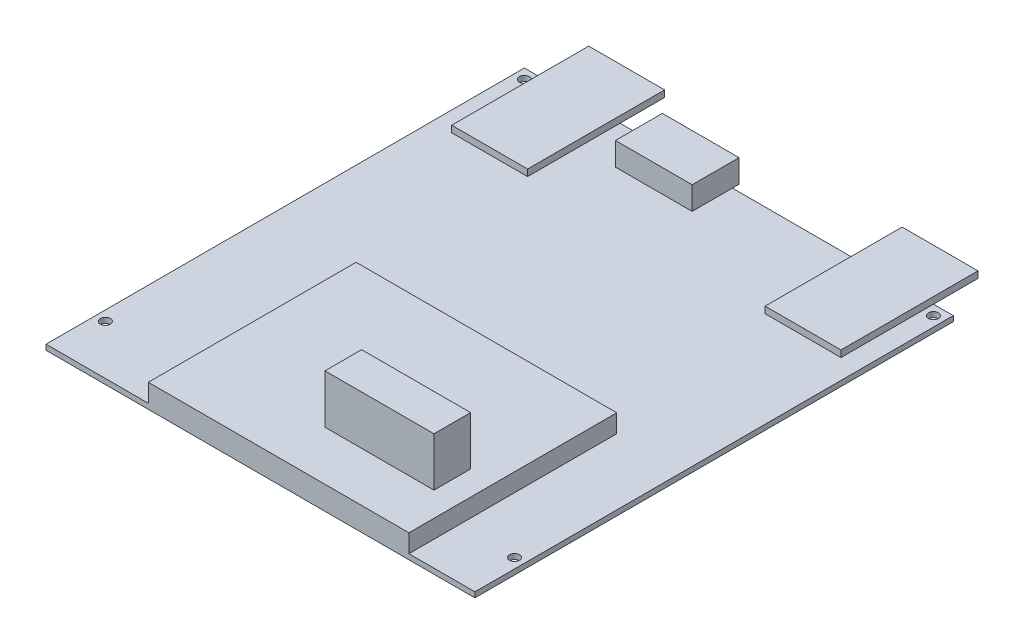
from build123d import *

# Parameters (mm, degrees)
ESQUISSE1_W        = 130
ESQUISSE1_H        = 145
ESQUISSE1_R        = 1.5
BOSS_EXTRU_1_DEPTH = 1.6
ESQUISSE2_W        = 79
ESQUISSE2_H        = 63
BOSS_EXTRU_2_DEPTH = 5.5
ESQUISSE3_W        = 33.047140846
ESQUISSE3_H        = 11.107836296
BOSS_EXTRU_3_DEPTH = 14.8
ESQUISSE4_W        = 23.239665889
ESQUISSE4_H        = 14.216628141
BOSS_EXTRU_4_DEPTH = 7
ESQUISSE5_W        = 23
ESQUISSE5_H        = 41.525911652
BOSS_EXTRU_5_DEPTH = 2
ESQUISSE6_W        = 6.210910455
ESQUISSE6_H        = 46.190495577
BOSS_EXTRU_6_DEPTH = 17.7
ESQUISSE7_W        = 68.5
ESQUISSE7_H        = 96
BOSS_EXTRU_7_DEPTH = 1.6
ESQUISSE8_W        = 5.226174608
ESQUISSE8_H        = 26.34937469
BOSS_EXTRU_8_DEPTH = 5


with BuildPart() as part:
    # Esquisse1 → Boss.-Extru.1 (new body)
    with BuildSketch(Plane(origin=(0, 0, 0), x_dir=(1, 0, 0), z_dir=(0, 1, 0))):
        with Locations((0, 72.5)):
            Rectangle(ESQUISSE1_W, ESQUISSE1_H)
        with Locations((-62, 142)):
            Circle(ESQUISSE1_R, mode=Mode.SUBTRACT)
        with Locations((62, 142)):
            Circle(ESQUISSE1_R, mode=Mode.SUBTRACT)
        with Locations((62, 15)):
            Circle(ESQUISSE1_R, mode=Mode.SUBTRACT)
        with Locations((-62, 15)):
            Circle(ESQUISSE1_R, mode=Mode.SUBTRACT)
    extrude(amount=BOSS_EXTRU_1_DEPTH)

    # Esquisse2 → Boss.-Extru.2 (add)
    with BuildSketch(Plane(origin=(0, 1.6, 0), x_dir=(1, 0, 0), z_dir=(0, 1, 0))):
        with Locations((5.5, 31.5)):
            Rectangle(ESQUISSE2_W, ESQUISSE2_H)
    extrude(amount=BOSS_EXTRU_2_DEPTH)

    # Esquisse3 → Boss.-Extru.3 (add)
    with BuildSketch(Plane(origin=(0, 7.1, 0), x_dir=(1, 0, 0), z_dir=(0, 1, 0))):
        with Locations((21.089415125, 20.538253018)):
            Rectangle(ESQUISSE3_W, ESQUISSE3_H)
    extrude(amount=BOSS_EXTRU_3_DEPTH)

    # Esquisse4 → Boss.-Extru.4 (add)
    with BuildSketch(Plane(origin=(0, 1.6, 0), x_dir=(1, 0, 0), z_dir=(0, 1, 0))):
        with Locations((-13.559579353, 139.891685929)):
            Rectangle(ESQUISSE4_W, ESQUISSE4_H)
    extrude(amount=BOSS_EXTRU_4_DEPTH)

    # Esquisse5 → Boss.-Extru.5 (add)
    with BuildSketch(Plane(origin=(0, 1.6, 0), x_dir=(1, 0, 0), z_dir=(0, 1, 0))):
        with Locations((-47.5, 137.737044174)):
            Rectangle(ESQUISSE5_W, ESQUISSE5_H)
        with Locations((47.5, 137.737044174)):
            Rectangle(ESQUISSE5_W, ESQUISSE5_H)
    extrude(amount=BOSS_EXTRU_5_DEPTH)

    # Esquisse6 → Boss.-Extru.6 (add)
    with BuildSketch(Plane.XZ):
        with Locations((20.563763626, -81.400742682)):
            Rectangle(ESQUISSE6_W, ESQUISSE6_H)
        with Locations((-20.563763626, -81.400742682)):
            Rectangle(ESQUISSE6_W, ESQUISSE6_H)
    extrude(amount=BOSS_EXTRU_6_DEPTH)

    # Esquisse7 → Boss.-Extru.7 (add)
    with BuildSketch(Plane.XZ.offset(17.7)):
        with Locations((0, -97)):
            Rectangle(ESQUISSE7_W, ESQUISSE7_H)
    extrude(amount=-BOSS_EXTRU_7_DEPTH)

    # Esquisse8 → Boss.-Extru.8 (add)
    with BuildSketch(Plane(origin=(0, -16.1, 0), x_dir=(1, 0, 0), z_dir=(0, 1, 0))):
        with Locations((-25.296871339, 147.825312655)):
            Rectangle(ESQUISSE8_W, ESQUISSE8_H)
    extrude(amount=BOSS_EXTRU_8_DEPTH)


solid = part.part
